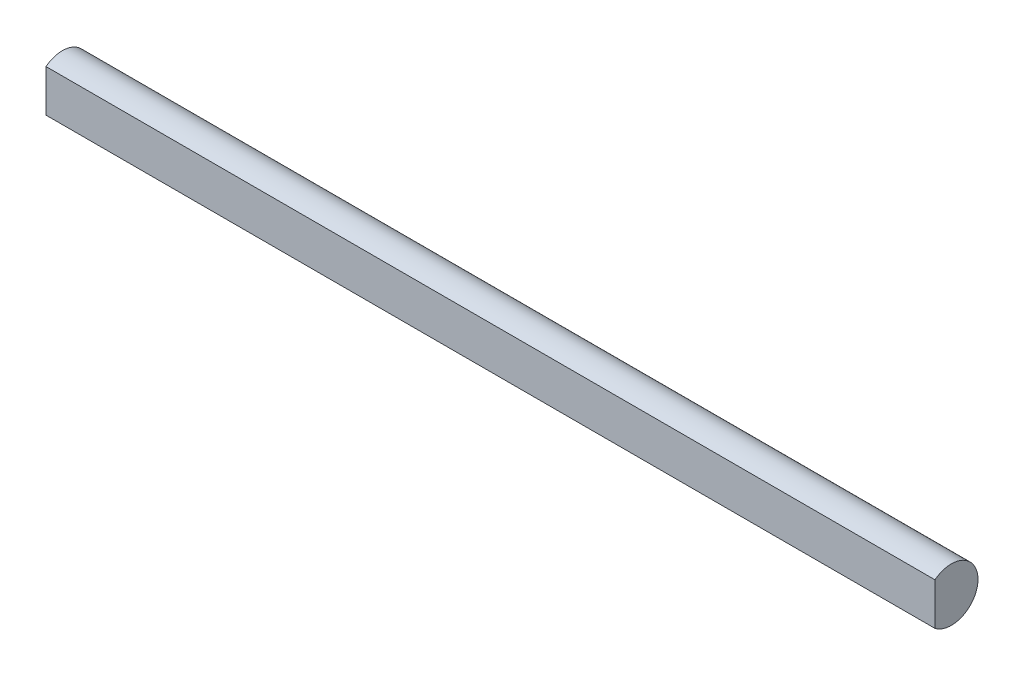
from build123d import *

# Parameters (mm, degrees)
BOSS_EXTRUDE1_DEPTH = 95


with BuildPart() as part:
    # Sketch1 → Boss-Extrude1 (new body)
    with BuildSketch(Plane(origin=(0, 0, 0), x_dir=(0, 0, -1), z_dir=(1, 0, 0))):
        with BuildLine():
            Line((-1.749285568, 2.25), (-1.749285568, -2.25))
            ThreePointArc((-1.749285568, -2.25), (2.85, 0), (-1.749285568, 2.25))
        make_face()
    extrude(amount=BOSS_EXTRUDE1_DEPTH)


solid = part.part
